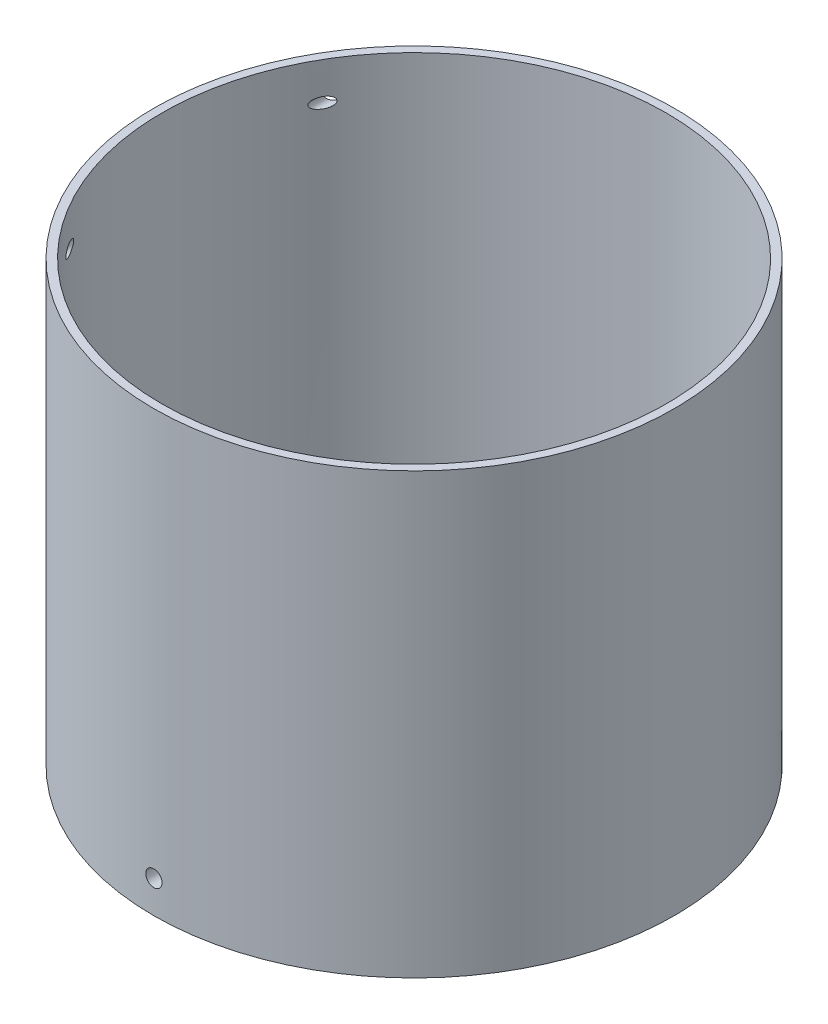
from build123d import *

# Parameters (mm, degrees)
SKETCH1_R               = 101.6
SKETCH1_R_2             = 95.25
BOSS_EXTRUDE1_DEPTH     = 25.4
SKETCH2_R               = 3.175
CUT_EXTRUDE1_DEPTH      = 102.6
CUT_EXTRUDE1_DEPTH_BACK = 102.6
SKETCH5_R               = 101.6
SKETCH5_R_2             = 98.425
BOSS_EXTRUDE2_DEPTH     = 146.05
SKETCH9_R               = 2.1
CUT_EXTRUDE5_DEPTH      = 204.2000001


with BuildPart() as part:
    # Sketch1 → Boss-Extrude1 (new body)
    with BuildSketch(Plane(origin=(0, 0, 0), x_dir=(1, 0, 0), z_dir=(0, 1, 0))):
        Circle(SKETCH1_R)
        Circle(SKETCH1_R_2, mode=Mode.SUBTRACT)
    extrude(amount=BOSS_EXTRUDE1_DEPTH)

    # Sketch2 → Cut-Extrude1 (cut, two sides)
    with BuildSketch(Plane.XY) as cut_extrude1_sk:
        with Locations((0, 12.7)):
            Circle(SKETCH2_R)
    extrude(amount=CUT_EXTRUDE1_DEPTH, mode=Mode.SUBTRACT)
    extrude(cut_extrude1_sk.sketch, amount=-CUT_EXTRUDE1_DEPTH_BACK, mode=Mode.SUBTRACT)

    # Sketch5 → Boss-Extrude2 (add)
    with BuildSketch(Plane(origin=(0, 25.4, 0), x_dir=(1, 0, 0), z_dir=(0, 1, 0))):
        Circle(SKETCH5_R)
        Circle(SKETCH5_R_2, mode=Mode.SUBTRACT)
    extrude(amount=BOSS_EXTRUDE2_DEPTH)

    # Sketch9 → Cut-Extrude5 (cut, through all)
    with BuildSketch(Plane.XY.offset(101.6)):
        with Locations((-85.075, 156.8)):
            Circle(SKETCH9_R)
    extrude(amount=-CUT_EXTRUDE5_DEPTH, mode=Mode.SUBTRACT)


solid = part.part
